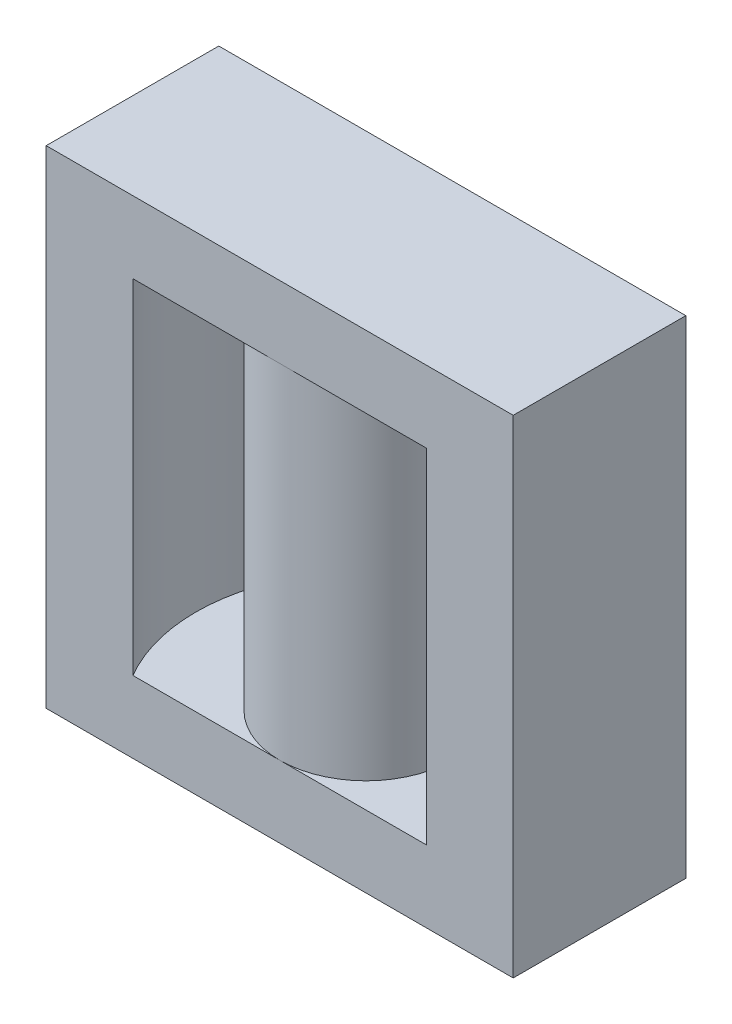
from build123d import *

# Parameters (mm, degrees)
BOSS_EXTRUDE1_DEPTH   = 62.4
SKETCH1_R             = 11.05
BOSS_EXTRUDE1_2_DEPTH = 62.4
BOSS_EXTRUDE1_3_DEPTH = 62.4
SKETCH2_W             = 59.8
SKETCH2_H             = 22.1
BOSS_EXTRUDE2_DEPTH   = 9.2
SKETCH3_W             = 59.8
SKETCH3_H             = 22.1
BOSS_EXTRUDE3_DEPTH   = 9.2


with BuildPart() as part:
    # Sketch1 → Boss-Extrude1 (new body)
    with BuildSketch(Plane(origin=(0, 0, 0), x_dir=(1, 0, 0), z_dir=(0, 1, 0))):
        with BuildLine():
            Line((-18.791953065, 11.05), (-29.9, 11.05))
            Line((-29.9, 11.05), (-29.9, -11.05))
            Line((-29.9, -11.05), (-18.791953065, -11.05))
            ThreePointArc((-18.791953065, -11.05), (-21.8, 0), (-18.791953065, 11.05))
        make_face()
    extrude(amount=BOSS_EXTRUDE1_DEPTH)



with BuildPart() as body_2:
    # Sketch1 → Boss-Extrude1 2 (new body)
    with BuildSketch(Plane(origin=(0, 0, 0), x_dir=(1, 0, 0), z_dir=(0, 1, 0))):
        Circle(SKETCH1_R)
    extrude(amount=BOSS_EXTRUDE1_2_DEPTH)


with BuildPart() as body_3:
    # Sketch1 → Boss-Extrude1 3 (new body)
    with BuildSketch(Plane(origin=(0, 0, 0), x_dir=(1, 0, 0), z_dir=(0, 1, 0))):
        with BuildLine():
            Line((29.9, 11.05), (18.791953065, 11.05))
            ThreePointArc((18.791953065, 11.05), (21.034549874, 5.7260555), (21.8, 0))
            ThreePointArc((21.8, 0), (21.034549874, -5.7260555), (18.791953065, -11.05))
            Line((18.791953065, -11.05), (29.9, -11.05))
            Line((29.9, -11.05), (29.9, 11.05))
        make_face()
    extrude(amount=BOSS_EXTRUDE1_3_DEPTH)


with BuildPart() as part_1:
    add(part.part)

    add(body_2.part)  # Boss-Extrude2 merges body 2

    add(body_3.part)  # Boss-Extrude2 merges body 3
    # Sketch2 → Boss-Extrude2 (add)
    with BuildSketch(Plane(origin=(0, 62.4, 0), x_dir=(1, 0, 0), z_dir=(0, 1, 0))):
        Rectangle(SKETCH2_W, SKETCH2_H)
    extrude(amount=-BOSS_EXTRUDE2_DEPTH)

    # Sketch3 → Boss-Extrude3 (add)
    with BuildSketch(Plane.XZ):
        Rectangle(SKETCH3_W, SKETCH3_H)
    extrude(amount=-BOSS_EXTRUDE3_DEPTH)


solid = part_1.part
